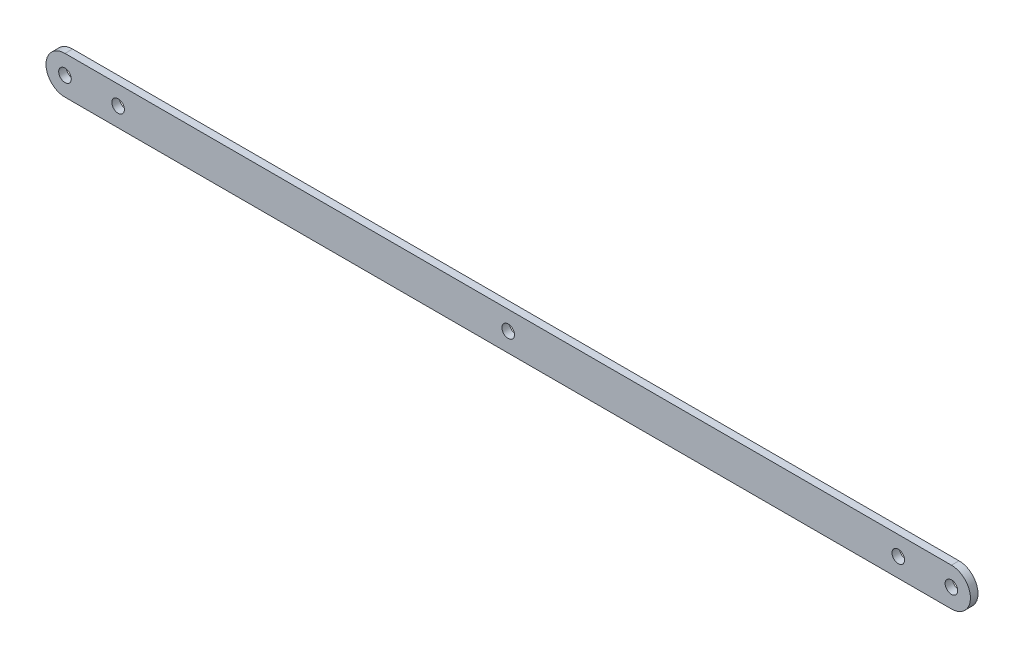
from build123d import *

# Parameters (mm, degrees)
SKICA1_R                = 4.15
P_IDAT_VYSUNUT_M1_DEPTH = 5


with BuildPart() as part:
    # Skica1 → Přidat vysunutím1 (new body)
    with BuildSketch(Plane.XY):
        with BuildLine():
            Line((0, 12.5), (584, 12.5))
            ThreePointArc((584, 12.5), (596.5, 0), (584, -12.5))
            Line((584, -12.5), (0, -12.5))
            ThreePointArc((0, -12.5), (-12.5, 0), (0, 12.5))
        make_face()
        Circle(SKICA1_R, mode=Mode.SUBTRACT)
        with Locations((584, 0)):
            Circle(SKICA1_R, mode=Mode.SUBTRACT)
        with Locations((35, 0)):
            Circle(SKICA1_R, mode=Mode.SUBTRACT)
        with Locations((292, 0)):
            Circle(SKICA1_R, mode=Mode.SUBTRACT)
        with Locations((549, 0)):
            Circle(SKICA1_R, mode=Mode.SUBTRACT)
    extrude(amount=P_IDAT_VYSUNUT_M1_DEPTH)


solid = part.part
